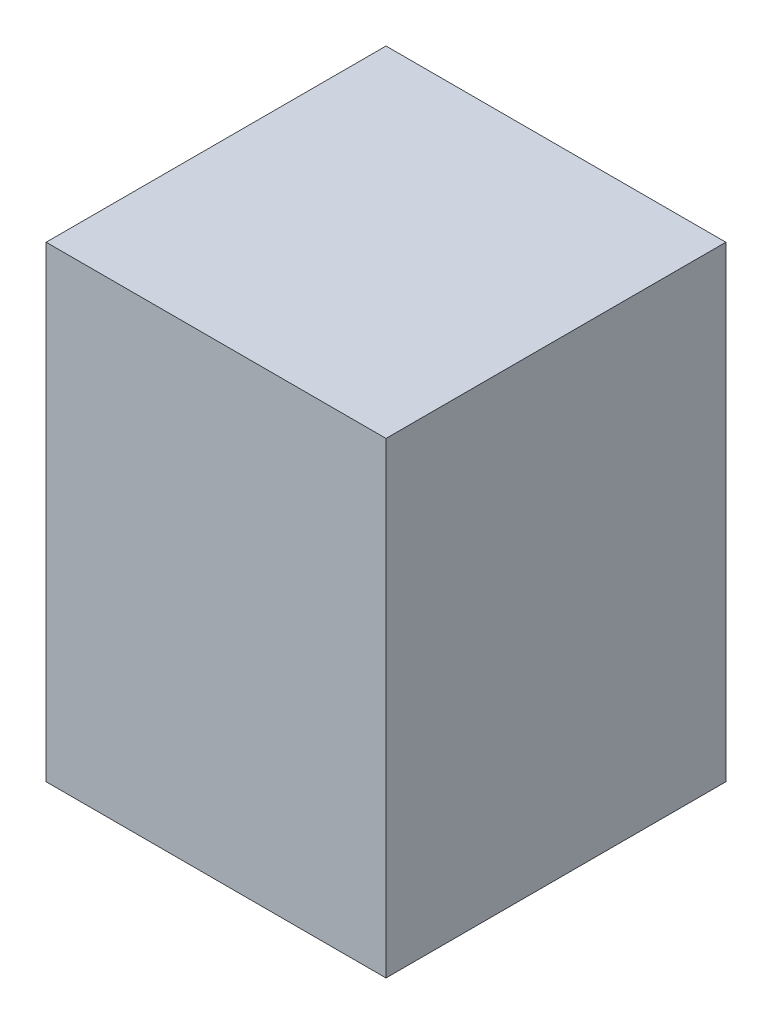
from build123d import *

# Parameters (mm, degrees)
CROQUIS1_W              = 800
CROQUIS1_H              = 1100
SALIENTE_EXTRUIR1_DEPTH = 800


with BuildPart() as part:
    # Croquis1 → Saliente-Extruir1 (new body)
    with BuildSketch(Plane.XY):
        with Locations((400, 550)):
            Rectangle(CROQUIS1_W, CROQUIS1_H)
    extrude(amount=SALIENTE_EXTRUIR1_DEPTH)


solid = part.part
